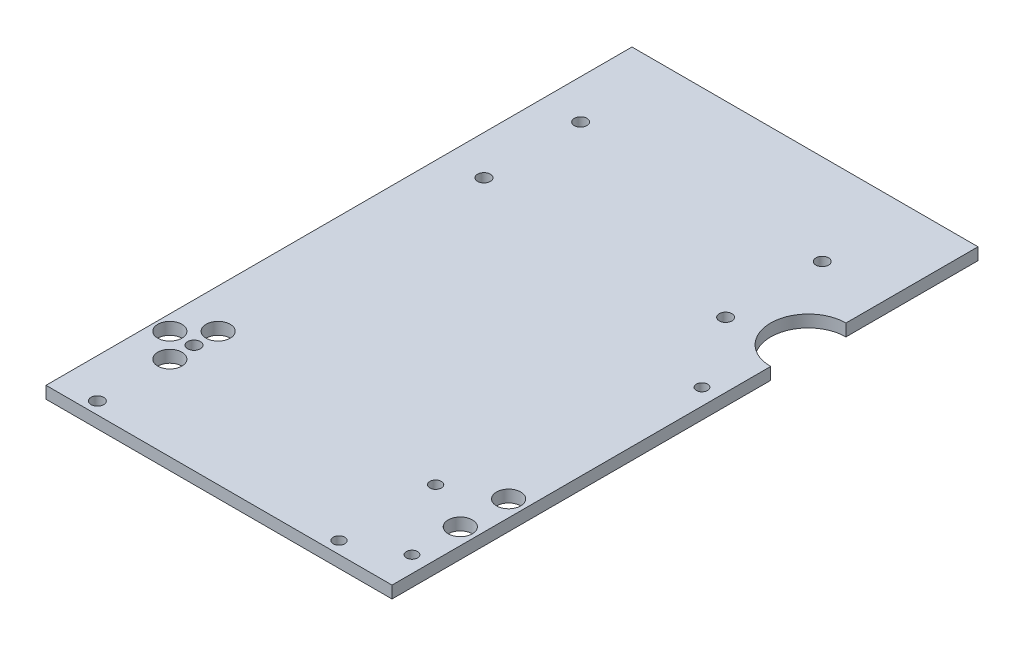
from build123d import *

# Parameters (mm, degrees)
SKETCH1_R           = 1.85
SKETCH1_R_2         = 1.905
SKETCH1_R_3         = 2.1
SKETCH1_R_4         = 4
BOSS_EXTRUDE1_DEPTH = 4


with BuildPart() as part:
    # Sketch1 → Boss-Extrude1 (new body)
    with BuildSketch(Plane(origin=(0, 0, 0), x_dir=(1, 0, 0), z_dir=(0, 1, 0))):
        with BuildLine():
            Line((-141, -139.759258716), (-26.44, -139.759258716))
            Line((-26.44, -139.759258716), (-26.44, -14.400783004))
            ThreePointArc((-26.44, -14.400783004), (-38.907528285, -1.933254719), (-26.44, 10.534273565))
            Line((-26.44, 10.534273565), (-26.44, 54.240741284))
            Line((-26.44, 54.240741284), (-141, 54.240741284))
            Line((-141, 54.240741284), (-141, -139.759258716))
        make_face()
        with Locations((-31.84, -31.759258716)):
            Circle(SKETCH1_R, mode=Mode.SUBTRACT)
        with Locations((-31.84, -127.759258716)):
            Circle(SKETCH1_R, mode=Mode.SUBTRACT)
        with Locations((-48, -135.759258716)):
            Circle(SKETCH1_R_2, mode=Mode.SUBTRACT)
        with Locations((-48, -103.759258716)):
            Circle(SKETCH1_R_2, mode=Mode.SUBTRACT)
        with Locations((-128, -135.759258716)):
            Circle(SKETCH1_R_3, mode=Mode.SUBTRACT)
        with Locations((-128, -103.759258716)):
            Circle(SKETCH1_R_3, mode=Mode.SUBTRACT)
        with Locations((-136, -103.759258716)):
            Circle(SKETCH1_R_4, mode=Mode.SUBTRACT)
        with Locations((-128, -95.759258716)):
            Circle(SKETCH1_R_4, mode=Mode.SUBTRACT)
        with Locations((-128, -111.759258716)):
            Circle(SKETCH1_R_4, mode=Mode.SUBTRACT)
        with Locations((-128, -7.759258716)):
            Circle(SKETCH1_R_3, mode=Mode.SUBTRACT)
        with Locations((-128, 24.240741284)):
            Circle(SKETCH1_R_3, mode=Mode.SUBTRACT)
        with Locations((-48, -7.759258716)):
            Circle(SKETCH1_R_3, mode=Mode.SUBTRACT)
        with Locations((-48, 24.240741284)):
            Circle(SKETCH1_R_3, mode=Mode.SUBTRACT)
        with Locations((-31.84, -111.759258716)):
            Circle(SKETCH1_R_4, mode=Mode.SUBTRACT)
        with Locations((-31.84, -95.759258716)):
            Circle(SKETCH1_R_4, mode=Mode.SUBTRACT)
    extrude(amount=-BOSS_EXTRUDE1_DEPTH)


solid = part.part
